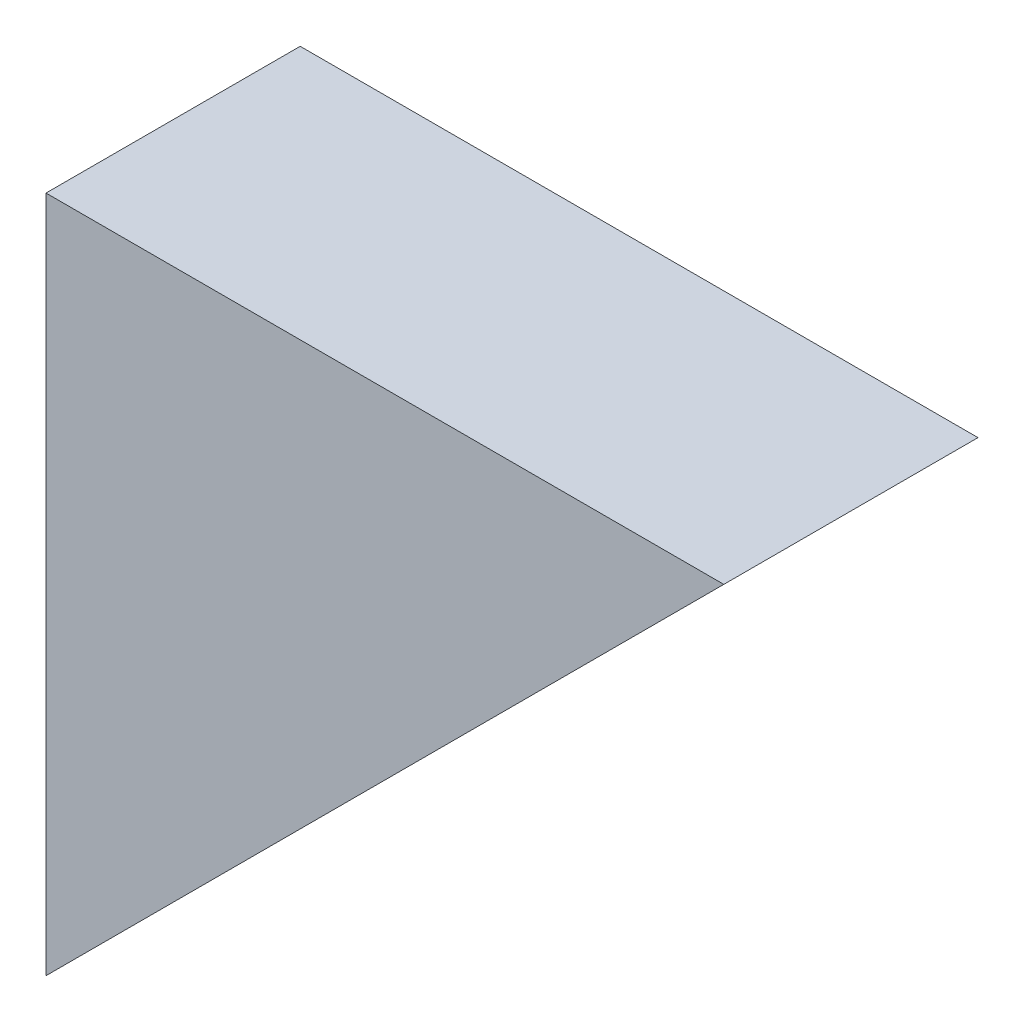
from build123d import *

# Parameters (mm, degrees)
BOSS_EXTRUDE1_DEPTH      = 19.05
BOSS_EXTRUDE1_DEPTH_BACK = 19.05


with BuildPart() as part:
    # Sketch1 → Boss-Extrude1 (new, two sides: drawn at the far end of the back side and taken through both)
    with BuildSketch(Plane.XY.offset(-BOSS_EXTRUDE1_DEPTH_BACK)):
        Polygon((0, 0), (101.6, 101.6), (0, 101.6), align=None)
    extrude(amount=BOSS_EXTRUDE1_DEPTH + BOSS_EXTRUDE1_DEPTH_BACK)


solid = part.part
